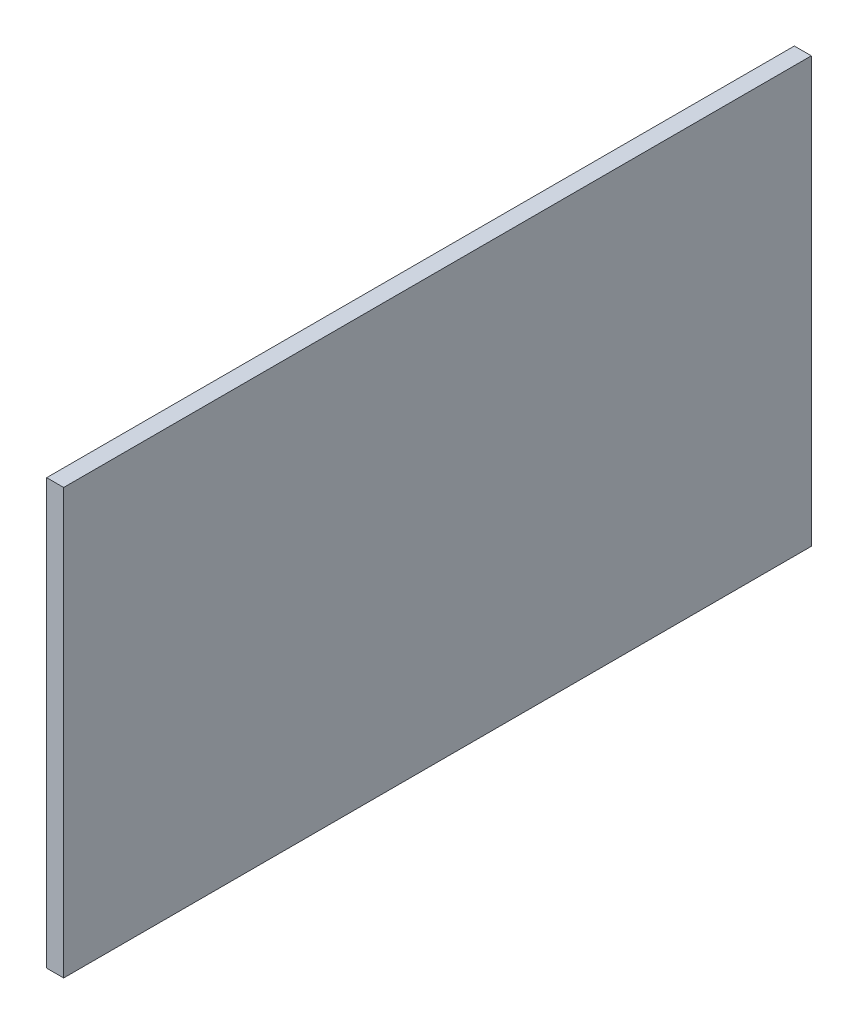
from build123d import *

# Parameters (mm, degrees)
SKETCH2_W           = 220
SKETCH2_H           = 125
BOSS_EXTRUDE1_DEPTH = 5


with BuildPart() as part:
    # Sketch2 → Boss-Extrude1 (new body)
    with BuildSketch(Plane(origin=(0, 0, 0), x_dir=(0, 0, -1), z_dir=(1, 0, 0))):
        with Locations((110, 62.5)):
            Rectangle(SKETCH2_W, SKETCH2_H)
    extrude(amount=-BOSS_EXTRUDE1_DEPTH)


solid = part.part
